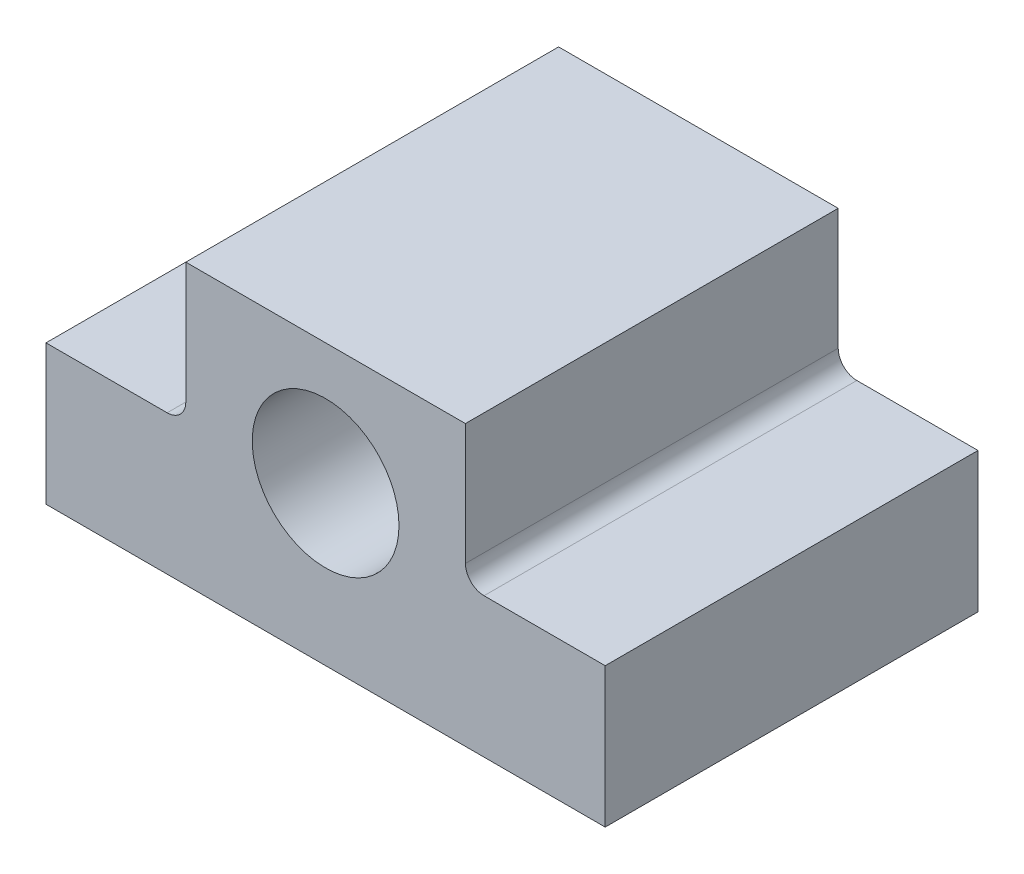
from build123d import *

# Parameters (mm, degrees)
SKETCH1_R           = 5
BOSS_EXTRUDE1_DEPTH = 12.7
FILLET1_R           = 1.27


with BuildPart() as part:
    # Sketch1 → Boss-Extrude1 (new body, symmetric)
    with BuildSketch(Plane.XY):
        Polygon((-19.05, 0), (19.05, 0), (19.05, 9.525), (9.525, 9.525), (9.525, 19.05), (-9.525, 19.05), (-9.525, 9.525), (-19.05, 9.525), align=None)
        with Locations((0, 10.764499551)):
            Circle(SKETCH1_R, mode=Mode.SUBTRACT)
    extrude(amount=BOSS_EXTRUDE1_DEPTH, both=True)

    # Fillet1
    fillet1_edges = [part.edges().sort_by_distance(p)[0] for p in [
        (-9.525, 9.525, 0),
        (9.525, 9.525, 0),
    ]]
    fillet(fillet1_edges, radius=FILLET1_R)


solid = part.part
